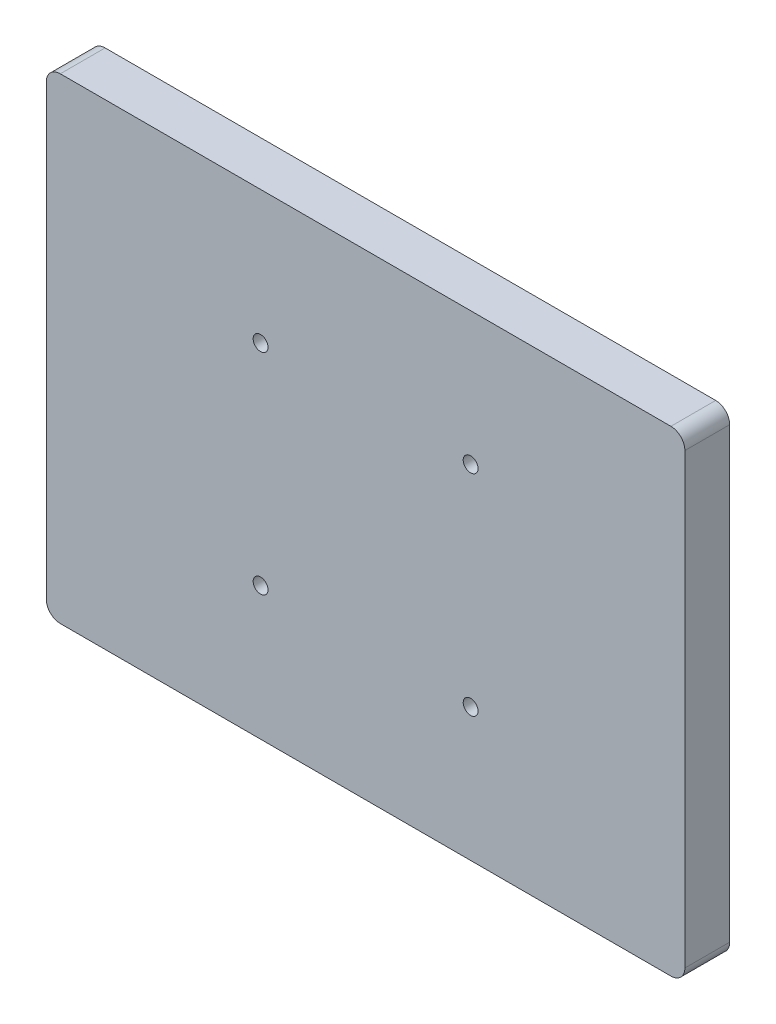
from build123d import *

# Parameters (mm, degrees)
SKETCH1_W           = 228
SKETCH1_H           = 170
BOSS_EXTRUDE1_DEPTH = 16
FILLET1_R           = 5
CUT_EXTRUDE1_REACH  = 18
SKETCH2_R           = 2.65


with BuildPart() as part:
    # Sketch1 → Boss-Extrude1 (new body)
    with BuildSketch(Plane.XY):
        with Locations((114, 85)):
            Rectangle(SKETCH1_W, SKETCH1_H)
    extrude(amount=BOSS_EXTRUDE1_DEPTH)

    # Fillet1
    fillet1_edges = [part.edges().sort_by_distance(p)[0] for p in [
        (0, 170, 8),
        (228, 170, 8),
        (228, 0, 8),
        (0, 0, 8),
    ]]
    fillet(fillet1_edges, radius=FILLET1_R)

    # Sketch2 → Cut-Extrude1 (cut, up to next)
    with BuildSketch(Plane.XY.offset(16), mode=Mode.PRIVATE) as cut_extrude1_sk1:
        with Locations((76.5, 122.5)):
            Circle(SKETCH2_R)
    cut_extrude1_tool1 = extrude(cut_extrude1_sk1.sketch, amount=-CUT_EXTRUDE1_REACH, mode=Mode.PRIVATE) & part.part
    add(cut_extrude1_tool1.solids().sort_by_distance((76.5, 122.5, 16))[0], mode=Mode.SUBTRACT)
    # Sketch2 → Cut-Extrude1 (cut, up to next)
    with BuildSketch(Plane.XY.offset(16), mode=Mode.PRIVATE) as cut_extrude1_sk2:
        with Locations((151.5, 122.5)):
            Circle(SKETCH2_R)
    cut_extrude1_tool2 = extrude(cut_extrude1_sk2.sketch, amount=-CUT_EXTRUDE1_REACH, mode=Mode.PRIVATE) & part.part
    add(cut_extrude1_tool2.solids().sort_by_distance((151.5, 122.5, 16))[0], mode=Mode.SUBTRACT)
    # Sketch2 → Cut-Extrude1 (cut, up to next)
    with BuildSketch(Plane.XY.offset(16), mode=Mode.PRIVATE) as cut_extrude1_sk3:
        with Locations((76.5, 47.5)):
            Circle(SKETCH2_R)
    cut_extrude1_tool3 = extrude(cut_extrude1_sk3.sketch, amount=-CUT_EXTRUDE1_REACH, mode=Mode.PRIVATE) & part.part
    add(cut_extrude1_tool3.solids().sort_by_distance((76.5, 47.5, 16))[0], mode=Mode.SUBTRACT)
    # Sketch2 → Cut-Extrude1 (cut, up to next)
    with BuildSketch(Plane.XY.offset(16), mode=Mode.PRIVATE) as cut_extrude1_sk4:
        with Locations((151.5, 47.5)):
            Circle(SKETCH2_R)
    cut_extrude1_tool4 = extrude(cut_extrude1_sk4.sketch, amount=-CUT_EXTRUDE1_REACH, mode=Mode.PRIVATE) & part.part
    add(cut_extrude1_tool4.solids().sort_by_distance((151.5, 47.5, 16))[0], mode=Mode.SUBTRACT)


solid = part.part
